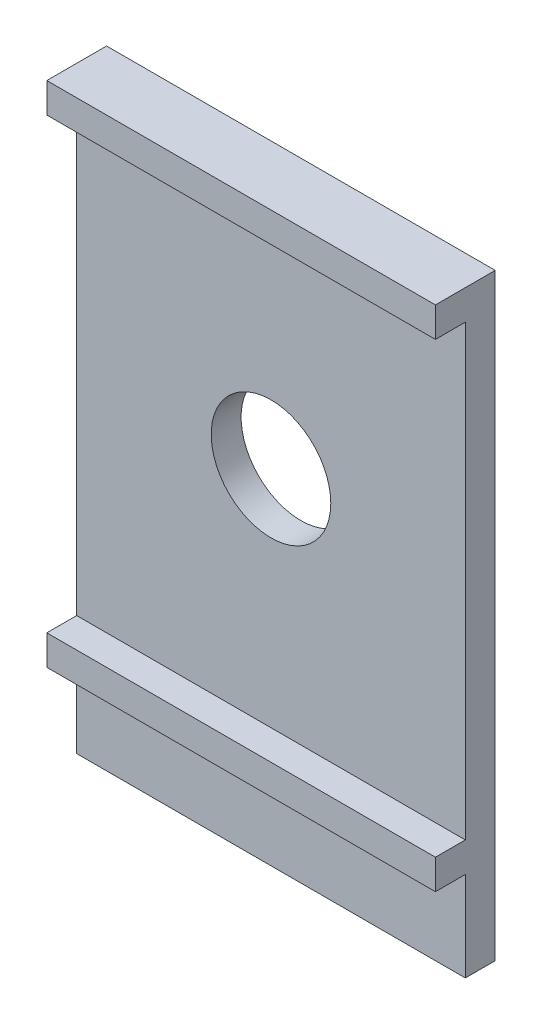
from build123d import *

# Parameters (mm, degrees)
SKICA1_W                 = 13
SKICA1_H                 = 23.5
P_IDAT_VYSUNUT_M1_DEPTH  = 1
SKICA2_W                 = 13
SKICA2_H                 = 1
P_IDAT_VYSUNUT_M2_DEPTH  = 1
SKICA3_R                 = 2
ODEBRAT_VYSUNUT_M1_DEPTH = 1
SKICA4_W                 = 13
SKICA4_H                 = 3.5
ODEBRAT_VYSUNUT_M2_DEPTH = 10


with BuildPart() as part:
    # Skica1 → Přidat vysunutím1 (new body)
    with BuildSketch(Plane.XY):
        with Locations((6.5, 11.75)):
            Rectangle(SKICA1_W, SKICA1_H)
    extrude(amount=P_IDAT_VYSUNUT_M1_DEPTH)

    # Skica2 → Přidat vysunutím2 (add)
    with BuildSketch(Plane.XY.offset(1)):
        with Locations((6.5, 23)):
            Rectangle(SKICA2_W, SKICA2_H)
        with Locations((6.5, 7)):
            Rectangle(SKICA2_W, SKICA2_H)
    extrude(amount=P_IDAT_VYSUNUT_M2_DEPTH)

    # Skica3 → Odebrat vysunutím1 (cut)
    with BuildSketch(Plane.XY.offset(1)):
        with Locations((6.5, 15)):
            Circle(SKICA3_R)
    extrude(amount=-ODEBRAT_VYSUNUT_M1_DEPTH, mode=Mode.SUBTRACT)

    # Skica4 → Odebrat vysunutím2 (cut)
    with BuildSketch(Plane.XY.offset(1)):
        with Locations((6.5, 1.75)):
            Rectangle(SKICA4_W, SKICA4_H)
    extrude(amount=-ODEBRAT_VYSUNUT_M2_DEPTH, mode=Mode.SUBTRACT)


solid = part.part
